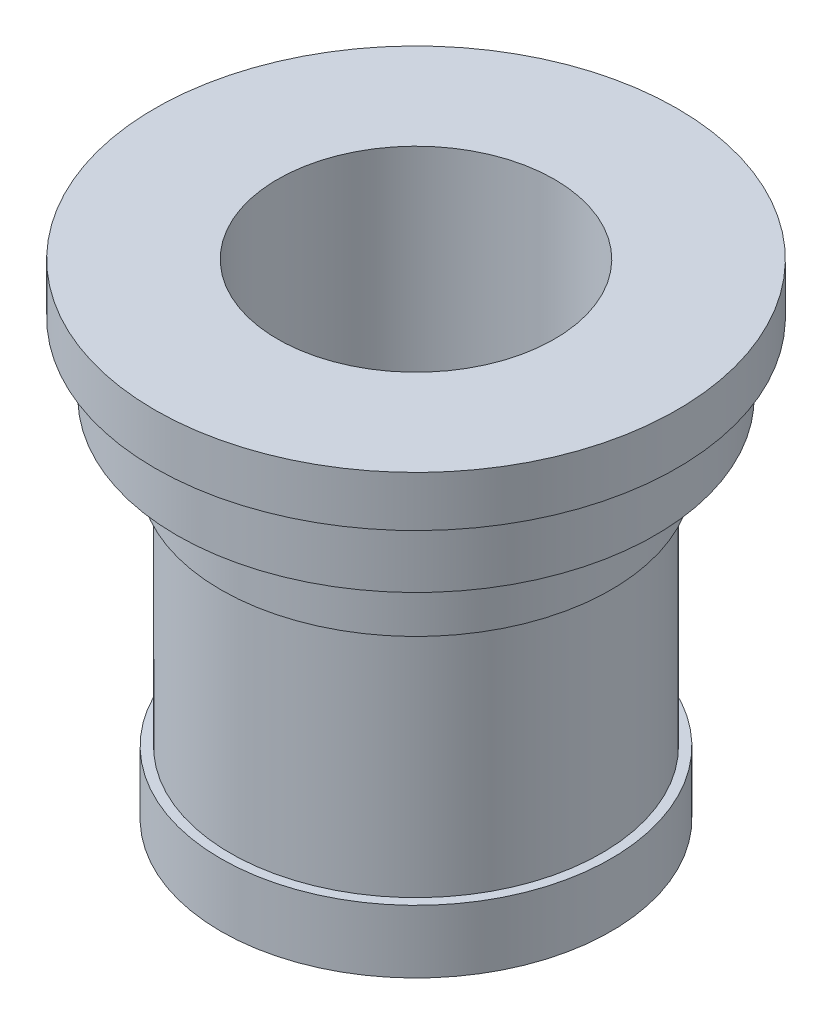
from build123d import *


with BuildPart() as part:
    # Sketch1 → Revolve1 (revolve)
    with BuildSketch(Plane.XY, mode=Mode.PRIVATE) as revolve1_sk:
        Polygon((22, 0), (31, 0), (31, 10), (29.5, 10), (29.5, 47), (31, 47), (31, 58), (38, 58), (38, 69), (41.5, 69), (41.5, 77), (22, 77), align=None)
    revolve(revolve1_sk.sketch.rotate(Axis((0, 0, 0), (0, 1, 0)), 90), axis=Axis((0, 0, 0), (0, 1, 0)))  # turned: the seam where the file's is


solid = part.part
